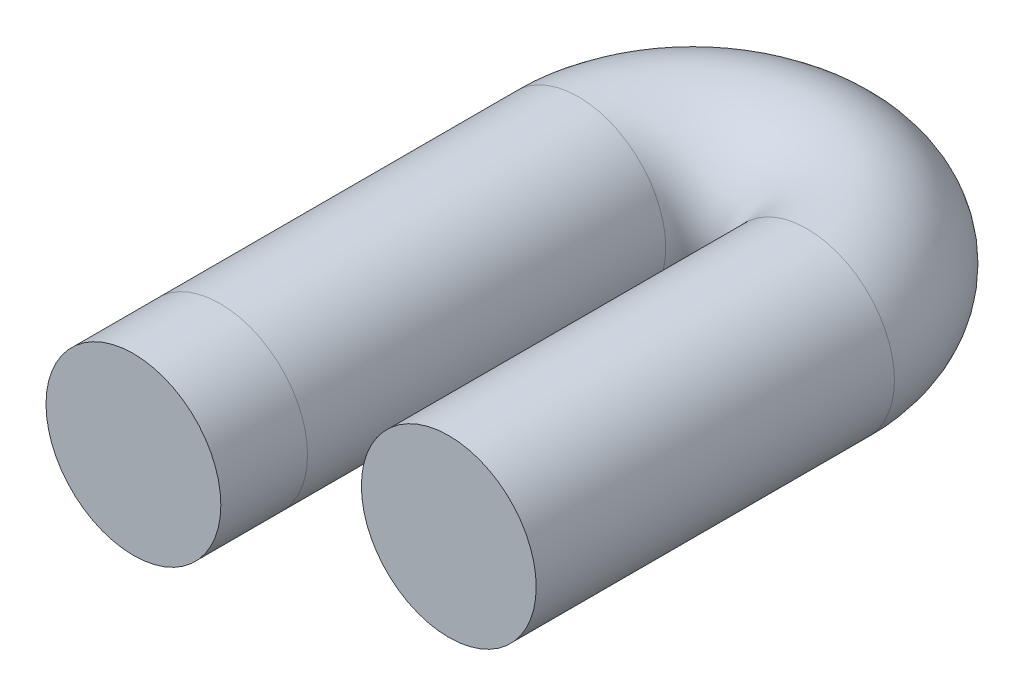
from build123d import *

# Parameters (mm, degrees)
SKETCH2_R = 20.903264374


with BuildPart() as part:
    # Sweep2: sweep along a path in Sketch3
    with BuildLine(Plane(origin=(0, 0, 0), x_dir=(1, 0, 0), z_dir=(0, 1, 0))) as sweep2_path:
        Line((0, 0), (0, 20.730621078))
        Line((0, 20.730621078), (0, 106.395646218))
        ThreePointArc((0, 106.395646218), (27.342049463, 133.737695681), (54.684098926, 106.395646218))
        Line((54.684098926, 106.395646218), (54.684098926, 20.730621078))
    # Sketch2 → Sweep2 (sweep)
    with BuildSketch(Plane.XY):
        Circle(SKETCH2_R)
    sweep(path=sweep2_path.line)


solid = part.part
